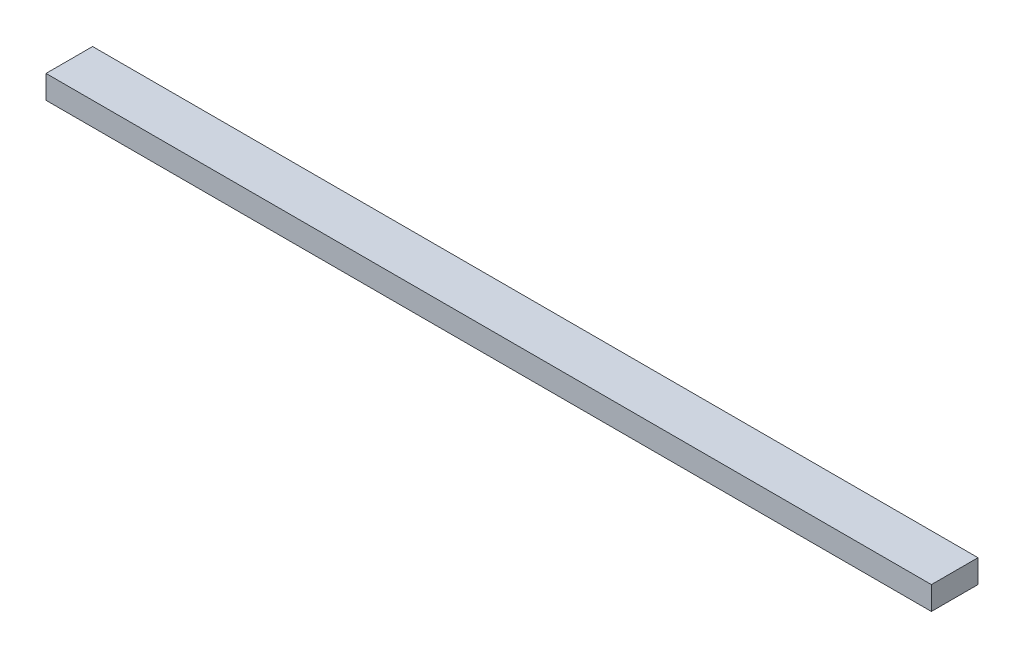
from build123d import *

# Parameters (mm, degrees)
SKETCH1_W           = 120.65
SKETCH1_H           = 6.35
BOSS_EXTRUDE1_DEPTH = 3.175


with BuildPart() as part:
    # Sketch1 → Boss-Extrude1 (new body)
    with BuildSketch(Plane(origin=(0, 0, 0), x_dir=(1, 0, 0), z_dir=(0, 1, 0))):
        with Locations((-60.325, 3.175)):
            Rectangle(SKETCH1_W, SKETCH1_H)
    extrude(amount=BOSS_EXTRUDE1_DEPTH)


solid = part.part
